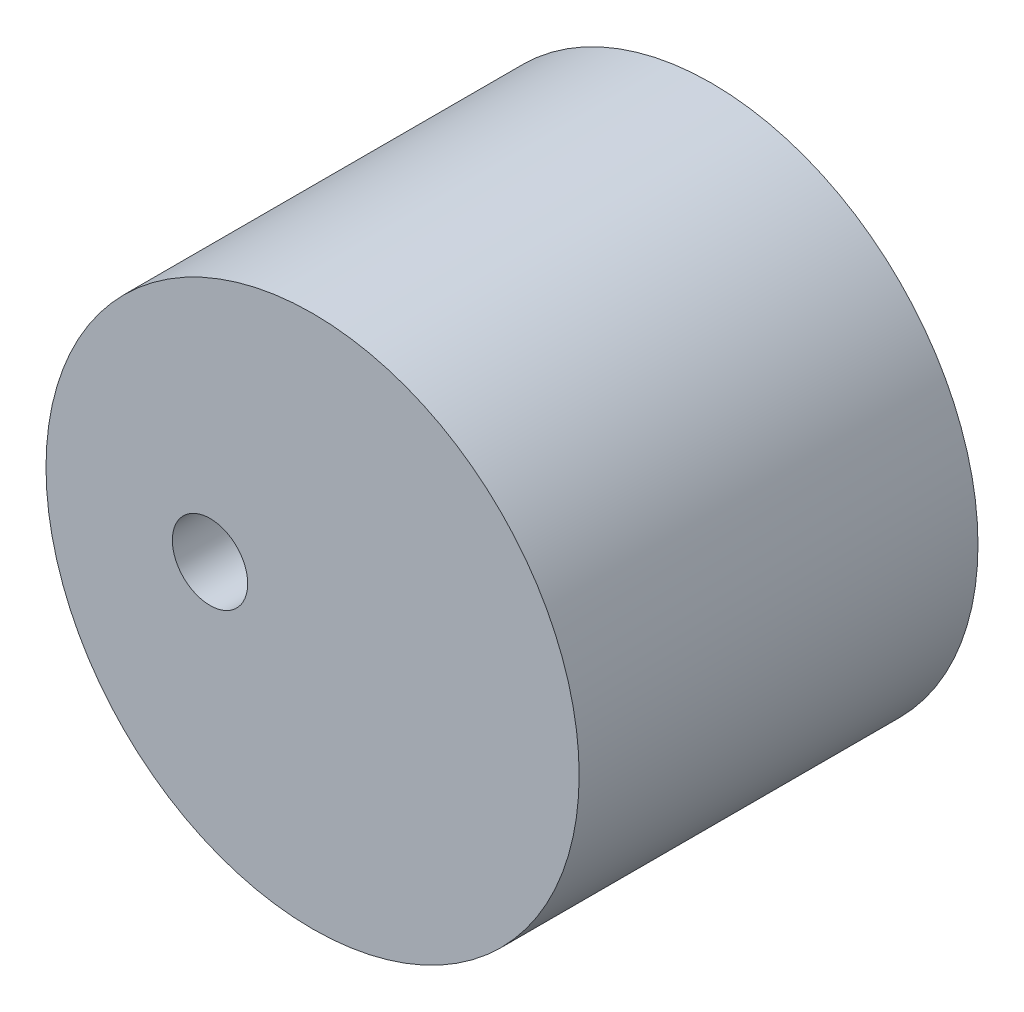
from build123d import *

# Parameters (mm, degrees)
SKETCH11_R           = 23.39375
SKETCH11_R_2         = 3.3085
BOSS_EXTRUDE13_DEPTH = 35


with BuildPart() as part:
    # Sketch11 → Boss-Extrude13 (new body)
    with BuildSketch(Plane.XY):
        Circle(SKETCH11_R)
        with Locations((-9, 0)):
            Circle(SKETCH11_R_2, mode=Mode.SUBTRACT)
    extrude(amount=BOSS_EXTRUDE13_DEPTH)


solid = part.part
